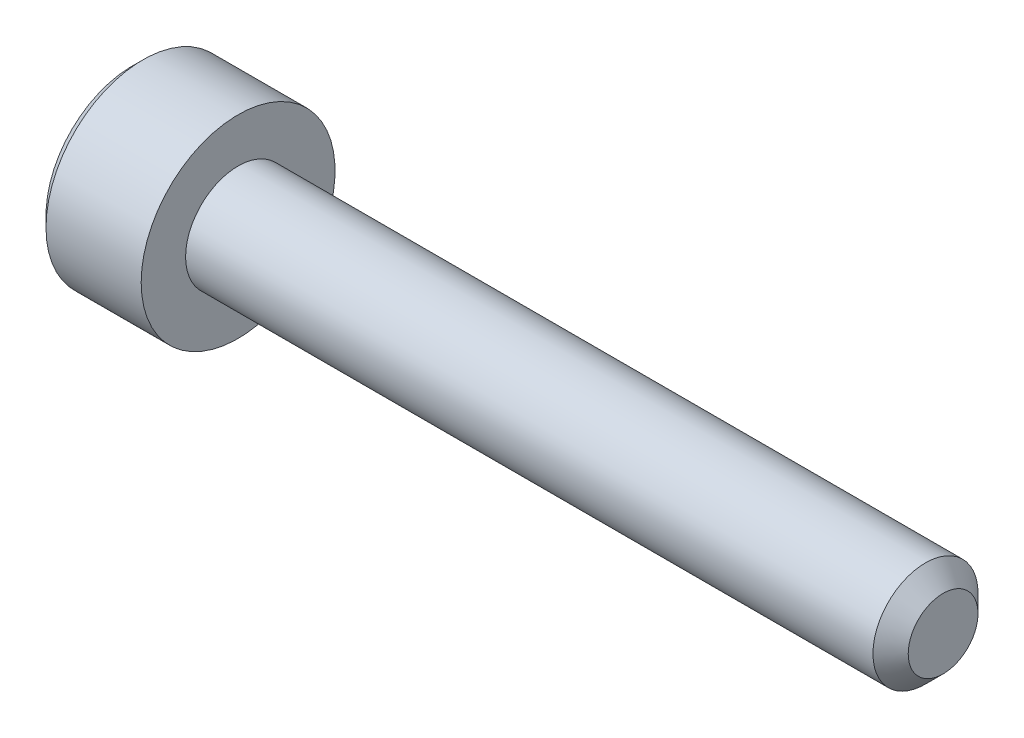
from build123d import *

# Parameters (mm, degrees)
CHAMFER1_SIZE      = 0.5
CHAMFER2_SIZE      = 0.3
CUT_EXTRUDE1_DEPTH = 2.5
CHAMFER3_SIZE      = 0.3


with BuildPart() as part:
    # Sketch1 → Revolve1 (revolve)
    with BuildSketch(Plane.XY):
        Polygon((0, 0), (0, 2.75), (3, 2.75), (3, 1.49), (23, 1.49), (23, 0), align=None)
    revolve(axis=Axis((-88.705490849, 0, 0), (1, 0, 0)))

    # Chamfer1
    chamfer1_edges = [part.edges().sort_by_distance(p)[0] for p in [
        (23, -1.49, 0),
    ]]
    chamfer(chamfer1_edges, length=CHAMFER1_SIZE)

    # Chamfer2
    chamfer2_edges = [part.edges().sort_by_distance(p)[0] for p in [
        (0, -2.75, 0),
    ]]
    chamfer(chamfer2_edges, length=CHAMFER2_SIZE)

    # Sketch3 → Cut-Extrude1 (cut)
    with BuildSketch(Plane(origin=(0, 0, 0), x_dir=(0, 0, -1), z_dir=(1, 0, 0))):
        Polygon((-1.443375673, 0), (-0.721687836, -1.25), (0.721687836, -1.25), (1.443375673, 0), (0.721687836, 1.25), (-0.721687836, 1.25), align=None)
    extrude(amount=CUT_EXTRUDE1_DEPTH, mode=Mode.SUBTRACT)

    # Chamfer3
    chamfer3_edges = [part.edges().sort_by_distance(p)[0] for p in [
        (0, 1.25, 0),
        (0, 0.625, 1.082531755),
        (0, -0.625, 1.082531755),
        (0, -1.25, 0),
        (0, -0.625, -1.082531755),
        (0, 0.625, -1.082531755),
    ]]
    chamfer(chamfer3_edges, length=CHAMFER3_SIZE)


solid = part.part
